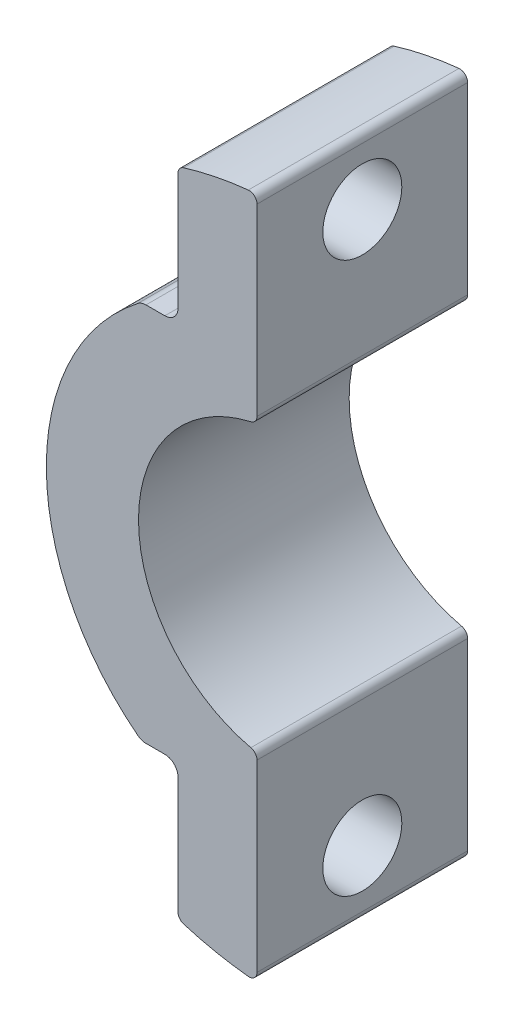
from build123d import *

# Parameters (mm, degrees)
ESQUISSE1_R             = 13
ESQUISSE1_R_2           = 5.5
BOSS_EXTRU_1_DEPTH      = 8
ESQUISSE2_W             = 32.31004566
ESQUISSE2_H             = 49.818141682
ENL_V_MAT_EXTRU_1_DEPTH = 8
ESQUISSE3_R             = 1.5
ENL_V_MAT_EXTRU_2_DEPTH = 8
ESQUISSE4_W             = 24.87123002
ESQUISSE4_H             = 13.833010023
ESQUISSE4_W_2           = 23.432073676
ESQUISSE4_H_2           = 10.309386407
ENL_V_MAT_EXTRU_3_DEPTH = 8
ENL_V_MAT_EXTRU_4_DEPTH = 8
CONG_1_R                = 0.5
CONG_3_R                = 0.3
CONG_4_R                = 0.5


with BuildPart() as part:
    # Esquisse1 → Boss.-Extru.1 (new body)
    with BuildSketch(Plane.XY):
        Circle(ESQUISSE1_R)
        Circle(ESQUISSE1_R_2, mode=Mode.SUBTRACT)
    extrude(amount=BOSS_EXTRU_1_DEPTH)

    # Esquisse2 → Enlèv. mat.-Extru.1 (cut)
    with BuildSketch(Plane.XY.offset(8)):
        with Locations((15.15502283, -0.665904075)):
            Rectangle(ESQUISSE2_W, ESQUISSE2_H)
    extrude(amount=-ENL_V_MAT_EXTRU_1_DEPTH, mode=Mode.SUBTRACT)

    # Esquisse3 → Enlèv. mat.-Extru.2 (cut)
    with BuildSketch(Plane(origin=(-1, 0, 0), x_dir=(0, 0, -1), z_dir=(1, 0, 0))):
        with Locations((-4, 10.461481397)):
            Circle(ESQUISSE3_R)
        with Locations((-4, -10.461481397)):
            Circle(ESQUISSE3_R)
    extrude(amount=-ENL_V_MAT_EXTRU_2_DEPTH, mode=Mode.SUBTRACT)

    # Esquisse4 → Enlèv. mat.-Extru.3 (cut)
    with BuildSketch(Plane.XY.offset(8)):
        with Locations((-16.43561501, 14.127986408)):
            Rectangle(ESQUISSE4_W, ESQUISSE4_H)
        with Locations((-15.716036838, -12.366174601)):
            Rectangle(ESQUISSE4_W_2, ESQUISSE4_H_2)
    extrude(amount=-ENL_V_MAT_EXTRU_3_DEPTH, mode=Mode.SUBTRACT)

    # Esquisse6 → Enlèv. mat.-Extru.4 (cut)
    with BuildSketch(Plane.XY.offset(8)):
        with BuildLine():
            Line((-15.190239973, -9.672332462), (-4.630180203, -7.717605282))
            ThreePointArc((-4.630180203, -7.717605282), (-8.999645968, -0.079827604), (-4.766352493, 7.63425726))
            Line((-4.766352493, 7.63425726), (-11.634503641, 11.269457117))
            ThreePointArc((-11.634503641, 11.269457117), (-18.222154917, 1.615222264), (-15.190239973, -9.672332462))
        make_face()
    extrude(amount=-ENL_V_MAT_EXTRU_4_DEPTH, mode=Mode.SUBTRACT)

    # Congé1
    cong_1_edges = [part.edges().sort_by_distance(p)[0] for p in [
        (-4, 7.211481397, 4),
        (-4, -7.211481397, 4),
    ]]
    fillet(cong_1_edges, radius=CONG_1_R)

    # Congé3
    cong_3_edges = [part.edges().sort_by_distance(p)[0] for p in [
        (-1, -5.408326913, 4),
        (-1, 5.408326913, 4),
        (-1, 12.961481397, 4),
        (-1, -12.961481397, 4),
        (-4, 12.369316877, 4),
        (-4, -12.369316877, 4),
    ]]
    fillet(cong_3_edges, radius=CONG_3_R)

    # Congé4
    cong_4_edges = [part.edges().sort_by_distance(p)[0] for p in [
        (-5.384657469, 7.211481397, 4),
        (-5.384657469, -7.211481397, 4),
    ]]
    fillet(cong_4_edges, radius=CONG_4_R)


solid = part.part
